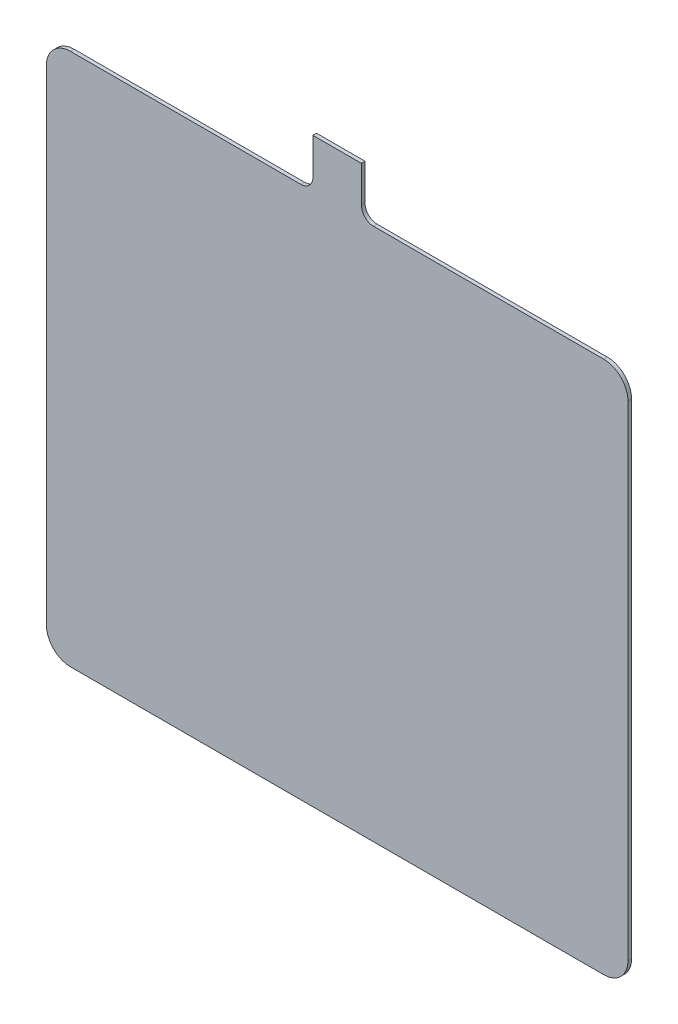
from build123d import *

# Parameters (mm, degrees)
BOSS_EXTRU_1_DEPTH = 3


with BuildPart() as part:
    # Esquisse1 → Boss.-Extru.1 (new body)
    with BuildSketch(Plane.XY):
        with BuildLine():
            Line((-220, 295), (-30, 295))
            ThreePointArc((-30, 295), (-22.928932188, 297.928932188), (-20, 305))
            Line((-20, 305), (-20, 335))
            Line((-20, 335), (20, 335))
            Line((20, 335), (20, 305))
            ThreePointArc((20, 305), (22.928932188, 297.928932188), (30, 295))
            Line((30, 295), (220, 295))
            ThreePointArc((220, 295), (234.142135624, 289.142135624), (240, 275))
            Line((240, 275), (240, -125))
            ThreePointArc((240, -125), (234.142135624, -139.142135624), (220, -145))
            Line((220, -145), (-220, -145))
            ThreePointArc((-220, -145), (-234.142135624, -139.142135624), (-240, -125))
            Line((-240, -125), (-240, 275))
            ThreePointArc((-240, 275), (-234.142135624, 289.142135624), (-220, 295))
        make_face()
    extrude(amount=BOSS_EXTRU_1_DEPTH)


solid = part.part
